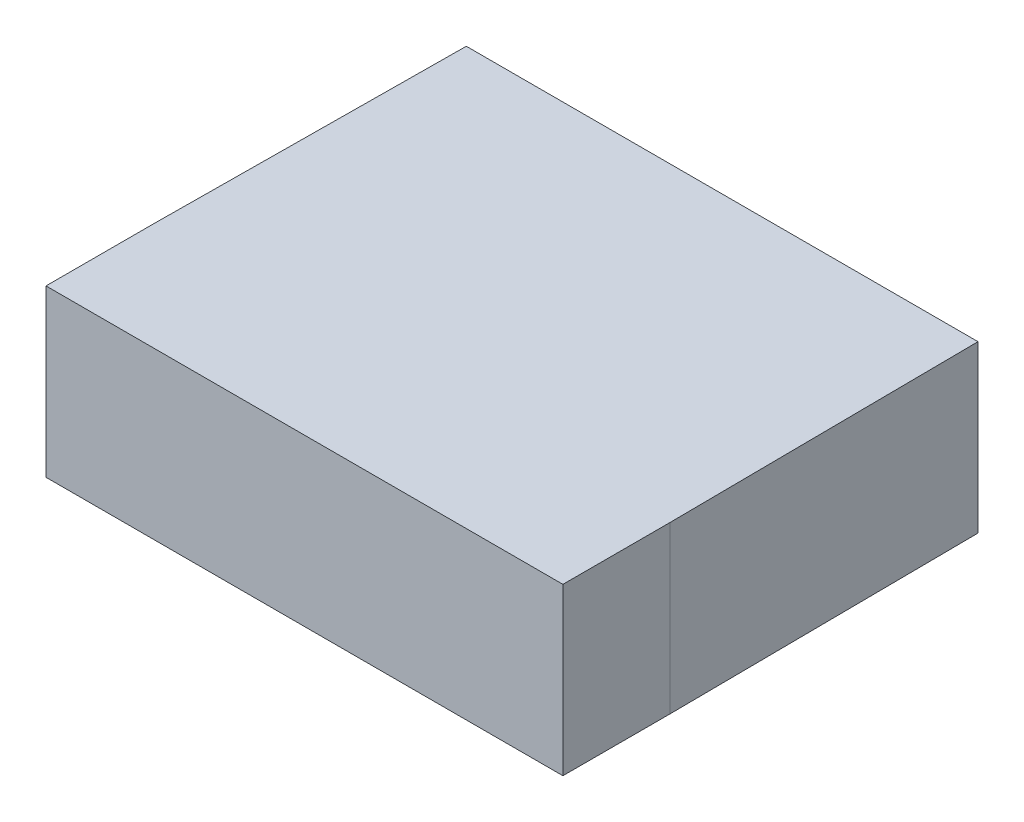
from build123d import *

# Parameters (mm, degrees)
BOSS_EXTRUDE1_DEPTH = 3.175


with BuildPart() as part:
    # Sketch1 → Boss-Extrude1 (new body)
    with BuildSketch(Plane(origin=(0, 0, 0), x_dir=(1, 0, 0), z_dir=(0, 1, 0))):
        Polygon((-4.9, 0), (4.9, 0), (4.95, -5.95), (4.95, -8), (-4.95, -8), (-4.95, -5.95), align=None)
    extrude(amount=BOSS_EXTRUDE1_DEPTH)


solid = part.part
